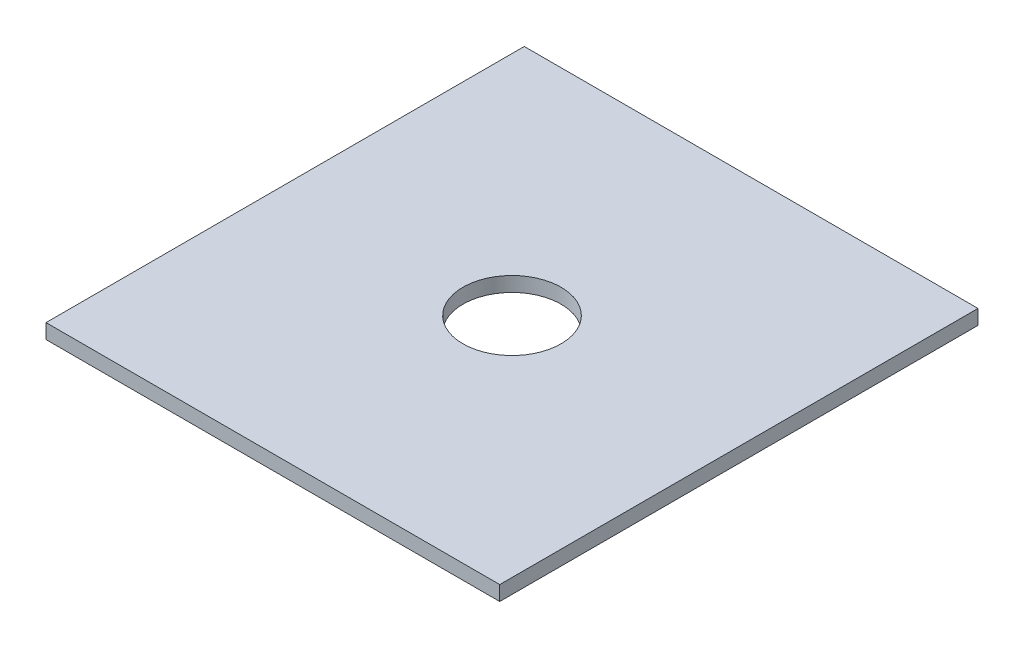
from build123d import *

# Parameters (mm, degrees)
SKETCH1_W           = 185
SKETCH1_H           = 195
SKETCH1_R           = 20
BOSS_EXTRUDE1_DEPTH = 6


with BuildPart() as part:
    # Sketch1 → Boss-Extrude1 (new body)
    with BuildSketch(Plane(origin=(0, 0, 0), x_dir=(1, 0, 0), z_dir=(0, 1, 0))):
        with Locations((-112.012195122, 9.512195122)):
            Rectangle(SKETCH1_W, SKETCH1_H)
        with Locations((-112.012195122, 9.512195122)):
            Circle(SKETCH1_R, mode=Mode.SUBTRACT)
    extrude(amount=BOSS_EXTRUDE1_DEPTH)


solid = part.part
